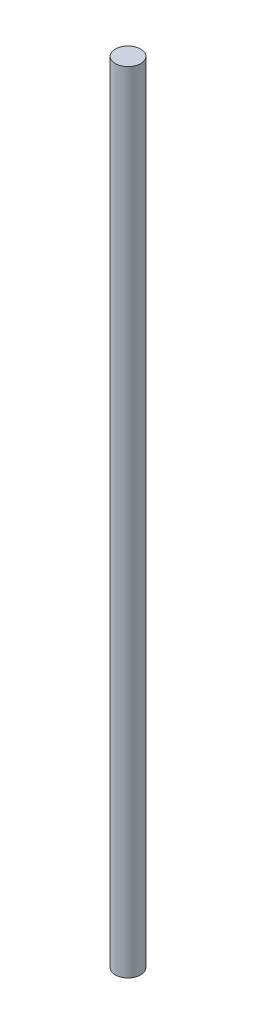
from build123d import *

# Parameters (mm, degrees)
CROQUIS1_R              = 4
SALIENTE_EXTRUIR1_DEPTH = 250


with BuildPart() as part:
    # Croquis1 → Saliente-Extruir1 (new body)
    with BuildSketch(Plane(origin=(0, 0, 0), x_dir=(1, 0, 0), z_dir=(0, 1, 0))):
        Circle(CROQUIS1_R)
    extrude(amount=SALIENTE_EXTRUIR1_DEPTH)


solid = part.part
